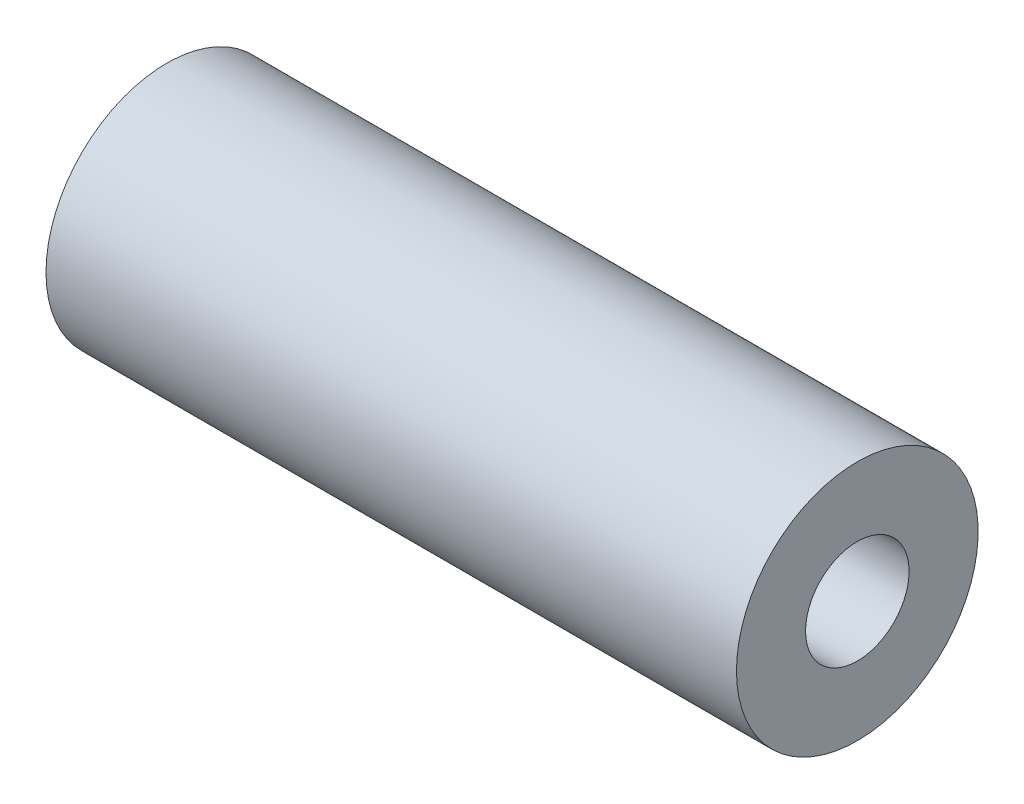
from build123d import *

# Parameters (mm, degrees)
SKETCH1_W = 40
SKETCH1_H = 4


with BuildPart() as part:
    # Sketch1 → Revolve1 (revolve)
    with BuildSketch(Plane.XY):
        with Locations((0, 5)):
            Rectangle(SKETCH1_W, SKETCH1_H)
    revolve(axis=Axis((-37.003163219, 0, 0), (1, 0, 0)))


solid = part.part
